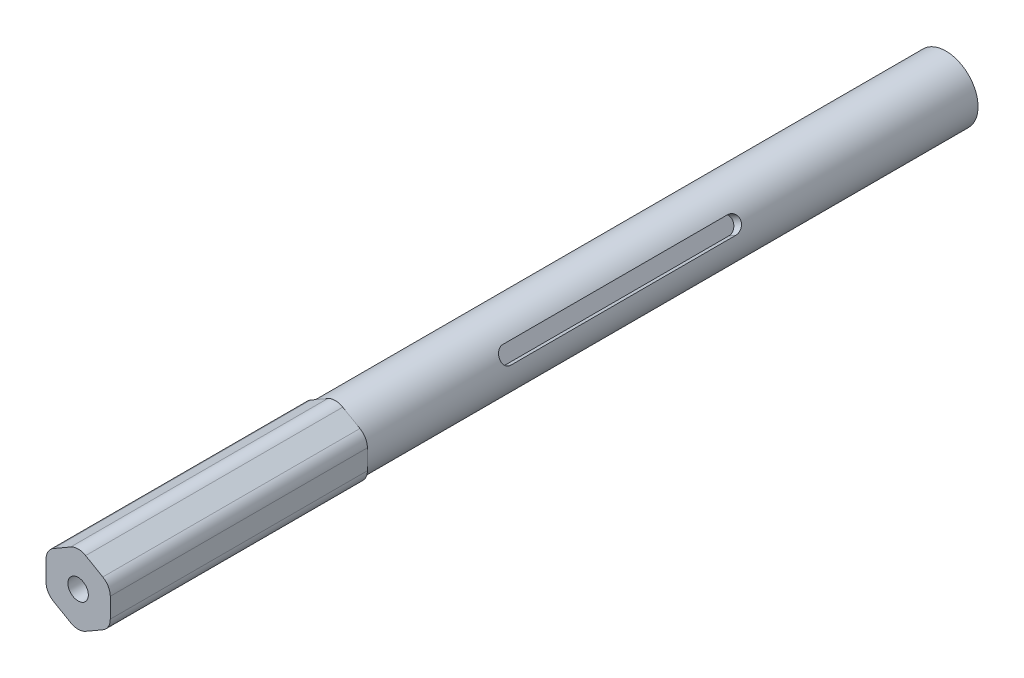
from build123d import *

# Parameters (mm, degrees)
BOSS_EXTRUDE1_DEPTH            = 171.45
FILLET1_R                      = 2.955
TAP_DRILL_FOR_10_32_TAP1_D     = 4.0386
TAP_DRILL_FOR_10_32_TAP1_DEPTH = 12.7
TAP_DRILL_FOR_10_32_TAP1_TIP   = 1.213317848
TAP_DRILL_FOR_10_32_TAP2_D     = 4.0386
TAP_DRILL_FOR_10_32_TAP2_DEPTH = 12.7
TAP_DRILL_FOR_10_32_TAP2_TIP   = 1.213317848
SKETCH12_OUTSIDE_W             = 49.194
SKETCH12_OUTSIDE_H             = 50.244
SKETCH12_OUTSIDE_R             = 6.35
CUT_EXTRUDE2_DEPTH             = 120.65
CUT_EXTRUDE3_DEPTH             = 1.9177


with BuildPart() as part:
    # Sketch3 → Boss-Extrude1 (new body)
    with BuildSketch(Plane.XY):
        Polygon((0, 7.332348419), (-6.35, 3.666174209), (-6.35, -3.666174209), (0, -7.332348419), (6.35, -3.666174209), (6.35, 3.666174209), align=None)
    extrude(amount=BOSS_EXTRUDE1_DEPTH)

    # Fillet1
    fillet1_edges = [part.edges().sort_by_distance(p)[0] for p in [
        (6.35, 3.666174209, 85.725),
        (6.35, -3.666174209, 85.725),
        (0, -7.332348419, 85.725),
        (-6.35, -3.666174209, 85.725),
        (-6.35, 3.666174209, 85.725),
        (0, 7.332348419, 85.725),
    ]]
    fillet(fillet1_edges, radius=FILLET1_R)

    # Tap Drill for #10-32 Tap1
    with Locations(Plane(origin=(0, 0, 0), x_dir=(-1, 0, 0), z_dir=(0, 0, -1))):
        with Locations((0, 0)):
            Hole(TAP_DRILL_FOR_10_32_TAP1_D / 2, depth=TAP_DRILL_FOR_10_32_TAP1_DEPTH)
            with Locations((0, 0, -(TAP_DRILL_FOR_10_32_TAP1_DEPTH + TAP_DRILL_FOR_10_32_TAP1_TIP / 2))):  # 118° drill point
                Cone(0, TAP_DRILL_FOR_10_32_TAP1_D / 2, TAP_DRILL_FOR_10_32_TAP1_TIP, mode=Mode.SUBTRACT)

    # Tap Drill for #10-32 Tap2
    with Locations(Plane.XY.offset(171.45)):
        with Locations((0, 0)):
            Hole(TAP_DRILL_FOR_10_32_TAP2_D / 2, depth=TAP_DRILL_FOR_10_32_TAP2_DEPTH)
            with Locations((0, 0, -(TAP_DRILL_FOR_10_32_TAP2_DEPTH + TAP_DRILL_FOR_10_32_TAP2_TIP / 2))):  # 118° drill point
                Cone(0, TAP_DRILL_FOR_10_32_TAP2_D / 2, TAP_DRILL_FOR_10_32_TAP2_TIP, mode=Mode.SUBTRACT)

    # Sketch12 outside → Cut-Extrude2 (cut)
    with BuildSketch(Plane(origin=(0, 0, 0), x_dir=(-1, 0, 0), z_dir=(0, 0, -1))):
        Rectangle(SKETCH12_OUTSIDE_W, SKETCH12_OUTSIDE_H)
        Circle(SKETCH12_OUTSIDE_R, mode=Mode.SUBTRACT)
    extrude(amount=-CUT_EXTRUDE2_DEPTH, mode=Mode.SUBTRACT)

    # Sketch13 → Cut-Extrude3 (cut)
    with BuildSketch(Plane(origin=(5.61125, 3.239656698, 0), x_dir=(0, 0, 1), z_dir=(-0.866025404, -0.5, 0))):
        with BuildLine():
            Line((92.075, 1.5875), (47.625, 1.5875))
            ThreePointArc((47.625, 1.5875), (46.0375, 0), (47.625, -1.5875))
            Line((47.625, -1.5875), (92.075, -1.5875))
            ThreePointArc((92.075, -1.5875), (93.6625, 0), (92.075, 1.5875))
        make_face()
    extrude(amount=CUT_EXTRUDE3_DEPTH, mode=Mode.SUBTRACT)


solid = part.part
